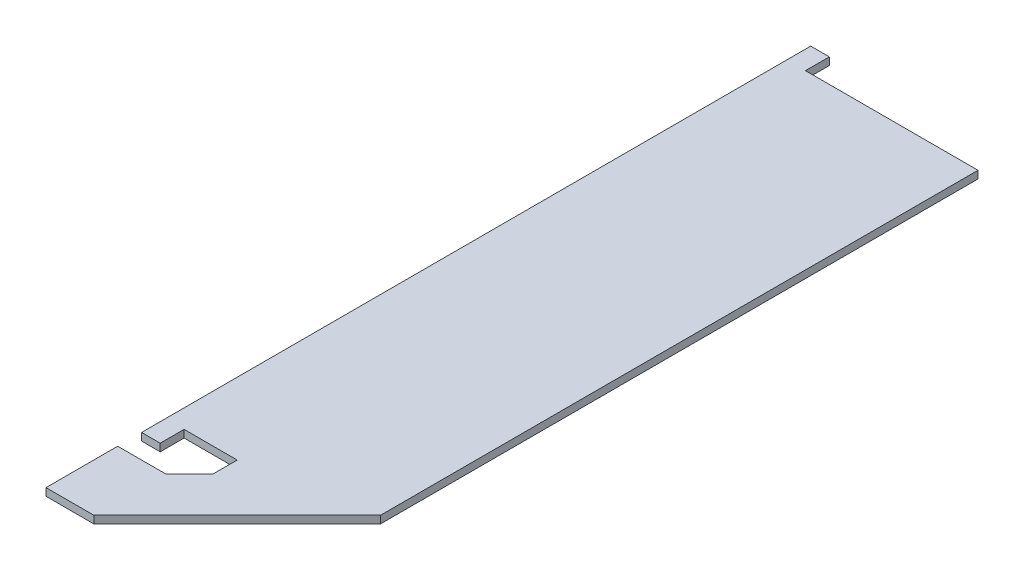
from build123d import *

# Parameters (mm, degrees)
BOSS_EXTRUDE1_DEPTH = 1.00076
SKETCH2_W           = 2.472118206
SKETCH2_H           = 1.00076
BOSS_EXTRUDE2_DEPTH = 3.175
CHAMFER2_SIZE       = 19.05
CHAMFER3_SIZE       = 3.175


with BuildPart() as part:
    # Sketch1 → Boss-Extrude1 (new body)
    with BuildSketch(Plane(origin=(0, 0, 0), x_dir=(1, 0, 0), z_dir=(0, 1, 0))):
        Polygon((-3.175, -41.275), (-3.175, -47.625), (-12.7, -47.625), (-12.7, -57.15), (12.7, -57.15), (12.7, -41.275), (12.7, 41.275), (-12.7, 41.275), (-12.7, -41.275), align=None)
    extrude(amount=BOSS_EXTRUDE1_DEPTH)

    # Sketch2 → Boss-Extrude2 (add)
    with BuildSketch(Plane.XY.offset(41.275)):
        with Locations((-11.463940897, 0.50038)):
            Rectangle(SKETCH2_W, SKETCH2_H)
    boss_extrude2 = extrude(amount=BOSS_EXTRUDE2_DEPTH)

    # Mirror1: Boss-Extrude2 across plane
    add(boss_extrude2.mirror(Plane.XY))

    # Chamfer2
    chamfer2_edges = [part.edges().sort_by_distance(p)[0] for p in [
        (12.7, 0.50038, 57.15),
    ]]
    chamfer(chamfer2_edges, length=CHAMFER2_SIZE)

    # Chamfer3
    chamfer3_edges = [part.edges().sort_by_distance(p)[0] for p in [
        (-3.175, 0.50038, 47.625),
    ]]
    chamfer(chamfer3_edges, length=CHAMFER3_SIZE)


solid = part.part
